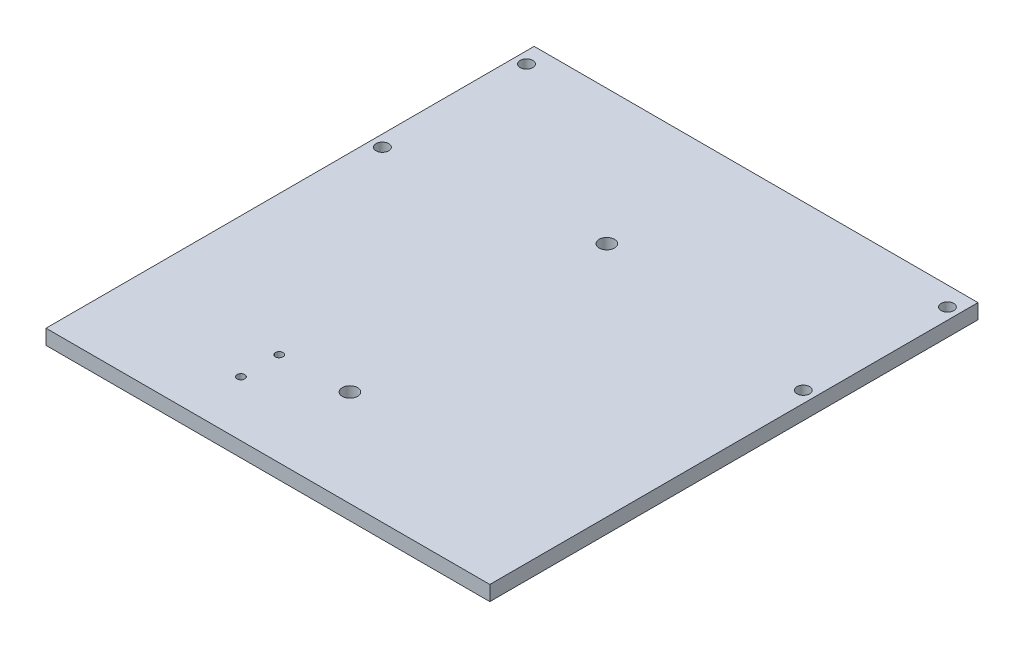
from build123d import *

# Parameters (mm, degrees)
SKETCH1_W           = 116.1
SKETCH1_H           = 47.7
BOSS_EXTRUDE1_DEPTH = 3.9
SKETCH4_R           = 1.65
CUT_EXTRUDE3_DEPTH  = 4.9
SKETCH5_R           = 1.65
CUT_EXTRUDE4_DEPTH  = 4.9
SKETCH7_W           = 116.1
SKETCH7_H           = 3.9
BOSS_EXTRUDE2_DEPTH = 80
SKETCH8_R           = 2
CUT_EXTRUDE5_DEPTH  = 4.9
SKETCH9_R           = 1
CUT_EXTRUDE6_DEPTH  = 4.9


with BuildPart() as part:
    # Sketch1 → Boss-Extrude1 (new body)
    with BuildSketch(Plane(origin=(0, 0, 0), x_dir=(1, 0, 0), z_dir=(0, 1, 0))):
        with Locations((58.05, 23.85)):
            Rectangle(SKETCH1_W, SKETCH1_H)
    extrude(amount=BOSS_EXTRUDE1_DEPTH)

    # Sketch4 → Cut-Extrude3 (cut, through all)
    with BuildSketch(Plane(origin=(0, 3.9, 0), x_dir=(1, 0, 0), z_dir=(0, 1, 0))):
        with Locations((3, 42.7)):
            Circle(SKETCH4_R)
    cut_extrude3 = extrude(amount=-CUT_EXTRUDE3_DEPTH, mode=Mode.SUBTRACT)

    # Sketch5 → Cut-Extrude4 (cut, through all)
    with BuildSketch(Plane(origin=(0, 3.9, 0), x_dir=(1, 0, 0), z_dir=(0, 1, 0))):
        with Locations((3, 5)):
            Circle(SKETCH5_R)
    cut_extrude4 = extrude(amount=-CUT_EXTRUDE4_DEPTH, mode=Mode.SUBTRACT)

    # Mirror1: Cut-Extrude3, Cut-Extrude4 across plane
    add(cut_extrude3.mirror(Plane.ZY.offset(-58.05)), mode=Mode.SUBTRACT)
    add(cut_extrude4.mirror(Plane.ZY.offset(-58.05)), mode=Mode.SUBTRACT)

    # Sketch7 → Boss-Extrude2 (add)
    with BuildSketch(Plane.XY):
        with Locations((58.05, 1.95)):
            Rectangle(SKETCH7_W, SKETCH7_H)
    extrude(amount=BOSS_EXTRUDE2_DEPTH)

    # Sketch8 → Cut-Extrude5 (cut, through all)
    with BuildSketch(Plane(origin=(0, 3.9, 0), x_dir=(1, 0, 0), z_dir=(0, 1, 0))):
        with Locations((54.2, -54.7)):
            Circle(SKETCH8_R)
        with Locations((54.2, 12.5)):
            Circle(SKETCH8_R)
    extrude(amount=-CUT_EXTRUDE5_DEPTH, mode=Mode.SUBTRACT)

    # Sketch9 → Cut-Extrude6 (cut, through all)
    with BuildSketch(Plane(origin=(0, 3.9, 0), x_dir=(1, 0, 0), z_dir=(0, 1, 0))):
        with Locations((36.5, -65.5)):
            Circle(SKETCH9_R)
        with Locations((36.5, -55.5)):
            Circle(SKETCH9_R)
    extrude(amount=-CUT_EXTRUDE6_DEPTH, mode=Mode.SUBTRACT)


solid = part.part
